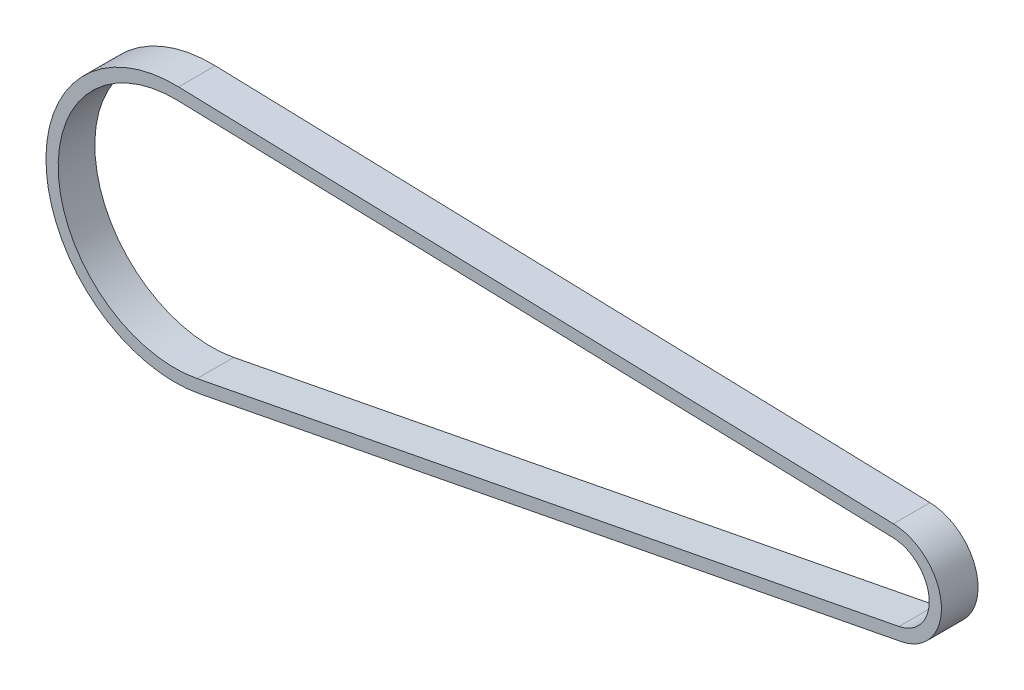
from build123d import *

# Parameters (mm, degrees)
BOSS_EXTRUDE1_DEPTH = 6


with BuildPart() as part:
    # Sketch1 → Boss-Extrude1 (new body)
    with BuildSketch(Plane.XY):
        with BuildLine():
            Line((0.619044099, 21.100921411), (117.699462987, 17.666097834))
            ThreePointArc((117.699462987, 17.666097834), (125.544914282, 10.217440864), (119.00714402, 1.598209072))
            Line((119.00714402, 1.598209072), (4.022884618, -20.723139225))
            ThreePointArc((4.022884618, -20.723139225), (-21.040434586, -1.712370408), (0.619044099, 21.100921411))
        make_face()
        with BuildLine():
            Line((0.560394729, 19.101781533), (117.640813617, 15.666957956))
            ThreePointArc((117.640813617, 15.666957956), (123.551505037, 10.05520776), (118.626008575, 3.561557175))
            Line((118.626008575, 3.561557175), (3.641749173, -18.759791122))
            ThreePointArc((3.641749173, -18.759791122), (-19.047025341, -1.550137305), (0.560394729, 19.101781533))
        make_face(mode=Mode.SUBTRACT)
    extrude(amount=BOSS_EXTRUDE1_DEPTH)


solid = part.part
